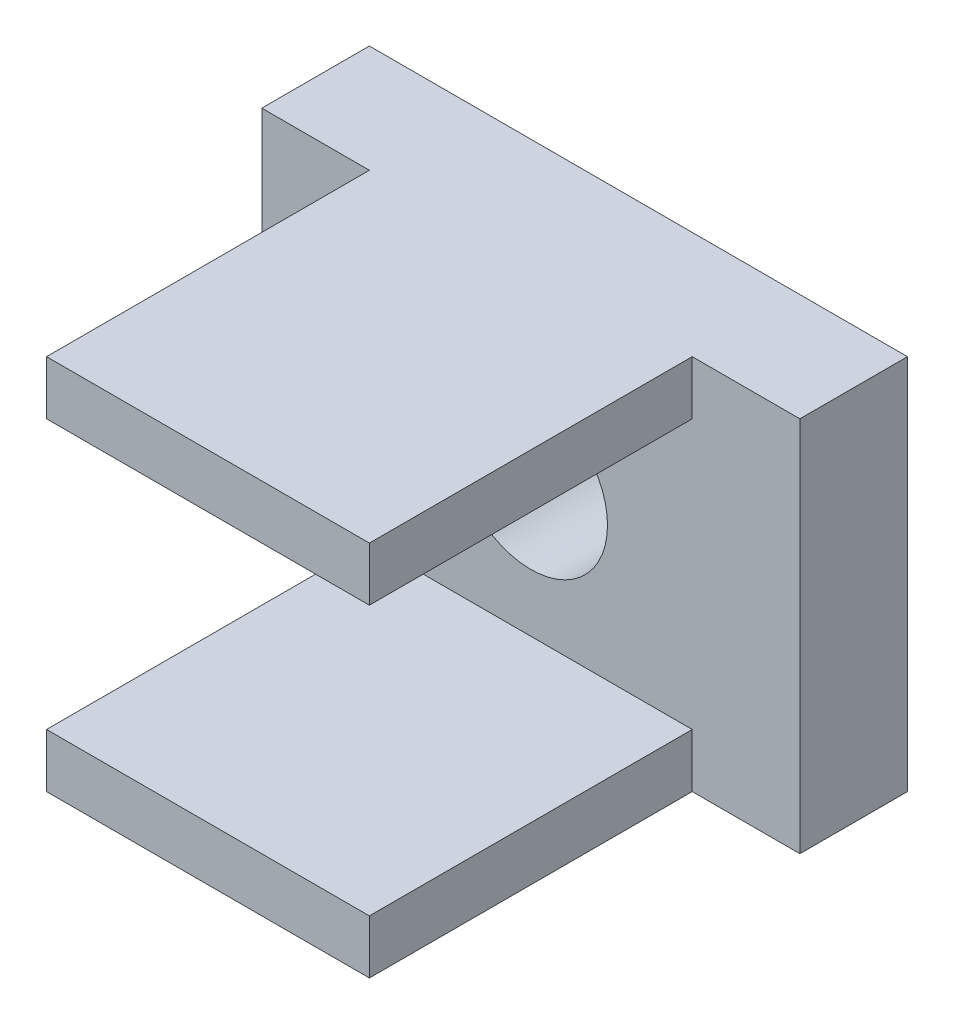
from build123d import *

# Parameters (mm, degrees)
SKETCH2_W           = 10
SKETCH2_H           = 7
BOSS_EXTRUDE1_DEPTH = 1
SKETCH3_R           = 1.425
CUT_EXTRUDE1_DEPTH  = 3
SKETCH4_W           = 6
SKETCH4_H           = 1
BOSS_EXTRUDE2_DEPTH = 6


with BuildPart() as part:
    # Sketch2 → Boss-Extrude1 (new body, symmetric)
    with BuildSketch(Plane.XY):
        Rectangle(SKETCH2_W, SKETCH2_H)
    extrude(amount=BOSS_EXTRUDE1_DEPTH, both=True)

    # Sketch3 → Cut-Extrude1 (cut, through all)
    with BuildSketch(Plane.XY.offset(1)):
        Circle(SKETCH3_R)
    extrude(amount=-CUT_EXTRUDE1_DEPTH, mode=Mode.SUBTRACT)

    # Sketch4 → Boss-Extrude2 (add)
    with BuildSketch(Plane.XY.offset(1)):
        with Locations((0, 3)):
            Rectangle(SKETCH4_W, SKETCH4_H)
        with Locations((0, -3)):
            Rectangle(SKETCH4_W, SKETCH4_H)
    extrude(amount=BOSS_EXTRUDE2_DEPTH)


solid = part.part
